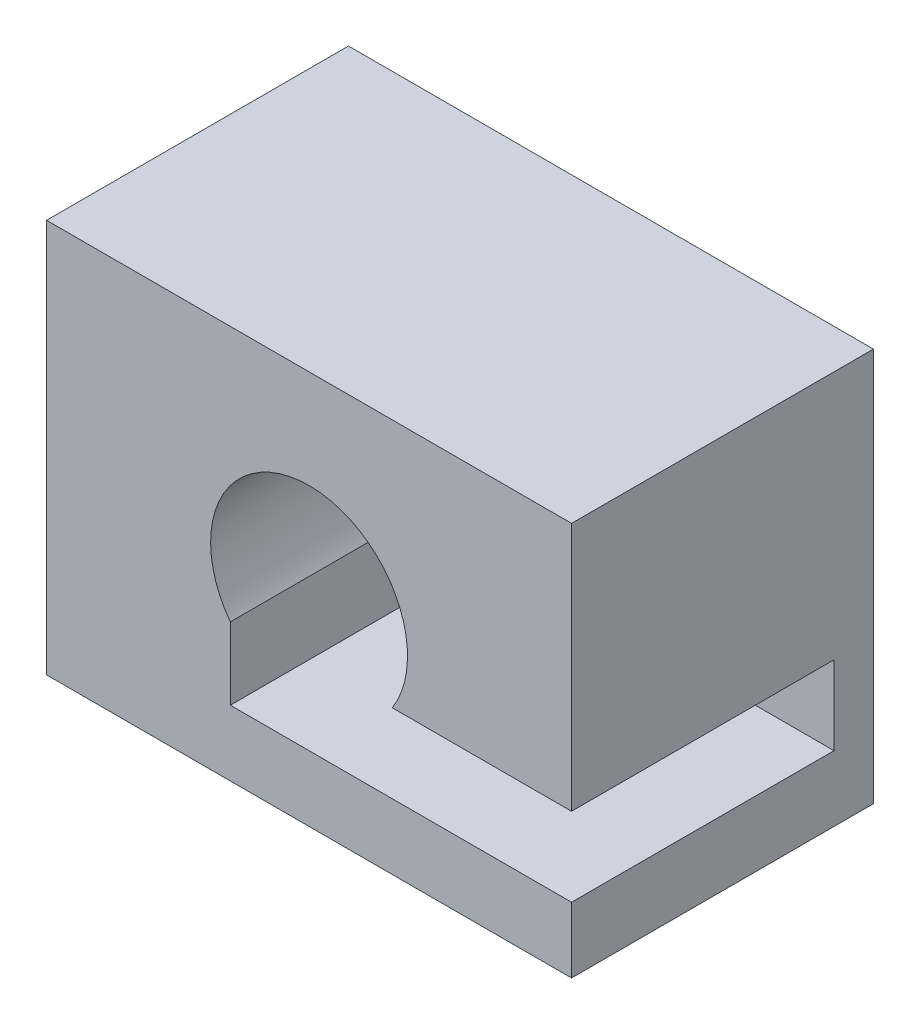
from build123d import *

# Parameters (mm, degrees)
SKETCH1_W           = 40
SKETCH1_H           = 30
BOSS_EXTRUDE1_DEPTH = 23
SKETCH3_R           = 6.1
CUT_EXTRUDE1_DEPTH  = 24
CUT_EXTRUDE2_DEPTH  = 20


with BuildPart() as part:
    # Sketch1 → Boss-Extrude1 (new body)
    with BuildSketch(Plane.XY):
        Rectangle(SKETCH1_W, SKETCH1_H)
    extrude(amount=BOSS_EXTRUDE1_DEPTH)

    # Sketch3 → Cut-Extrude1 (cut, through all)
    with BuildSketch(Plane.XY.offset(23)):
        Circle(SKETCH3_R)
    extrude(amount=-CUT_EXTRUDE1_DEPTH, mode=Mode.SUBTRACT)

    # Sketch4 → Cut-Extrude2 (cut)
    with BuildSketch(Plane.XY.offset(23)):
        with BuildLine():
            Line((-6, -4.5), (-6, -4))
            Line((-6, -4), (-4.605431576, -4))
            ThreePointArc((-4.605431576, -4), (-2.135048874, 5.714154907), (6.1, 0))
            ThreePointArc((6.1, 0), (5.714154907, -2.135048874), (4.605431576, -4))
            Line((4.605431576, -4), (6.34428877, -4))
            ThreePointArc((6.34428877, -4), (7.205281597, -2.081806214), (7.5, 0))
            ThreePointArc((7.5, 0), (-2.371708245, 7.115124735), (-6, -4.5))
        make_face()
        with BuildLine():
            Line((-4.605431576, -4), (-6, -4))
            Line((-6, -4), (-6, -4.5))
            ThreePointArc((-6, -4.5), (0.303535318, -7.493855237), (6.34428877, -4))
            Line((6.34428877, -4), (4.605431576, -4))
            ThreePointArc((4.605431576, -4), (0, -6.1), (-4.605431576, -4))
        make_face()
        with BuildLine():
            ThreePointArc((6.34428877, -4), (0.303535318, -7.493855237), (-6, -4.5))
            Line((-6, -4.5), (-6, -10))
            Line((-6, -10), (20, -10))
            Line((20, -10), (20, -4))
            Line((20, -4), (6.34428877, -4))
        make_face()
    extrude(amount=-CUT_EXTRUDE2_DEPTH, mode=Mode.SUBTRACT)


solid = part.part
